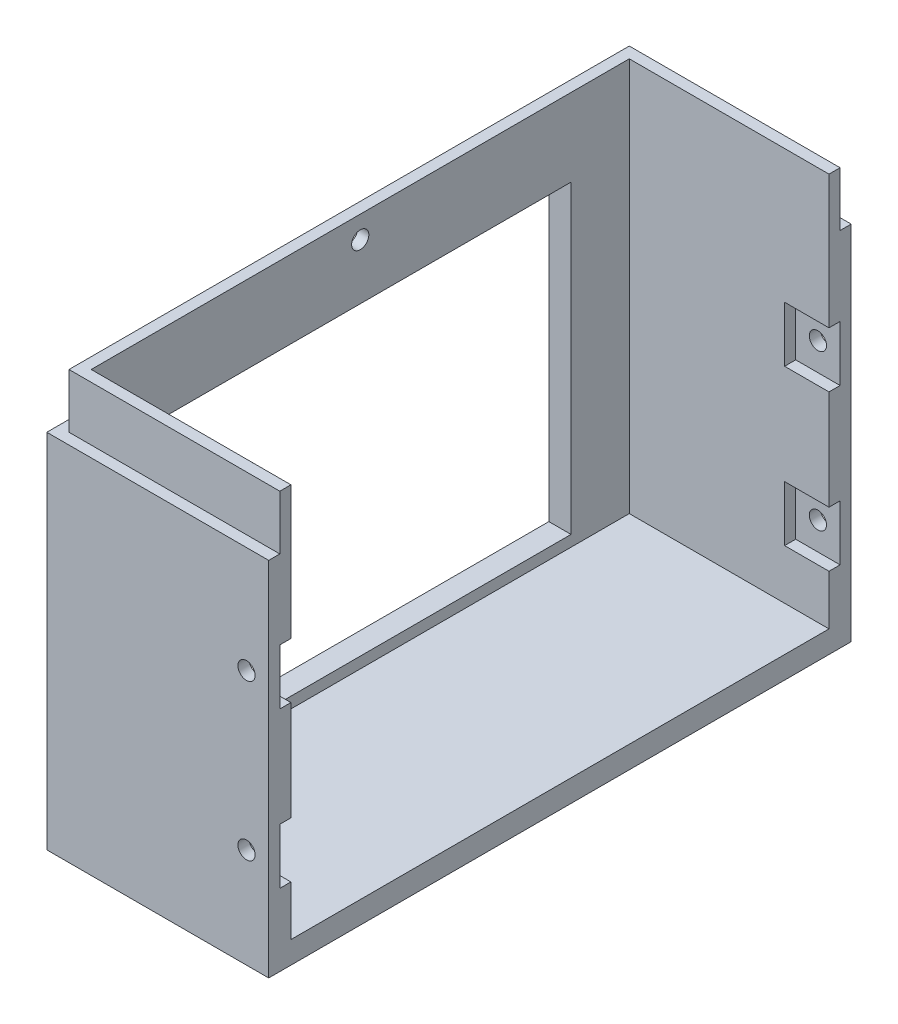
from build123d import *

# Parameters (mm, degrees)
SKETCH1_W               = 40
SKETCH1_H               = 105
BOSS_EXTRUDE3_DEPTH     = 75
SKETCH4_W               = 97
SKETCH4_H               = 71
CUT_EXTRUDE2_DEPTH      = 36
SKETCH5_W               = 40
SKETCH5_H               = 9.8
CUT_EXTRUDE3_DEPTH      = 2
SKETCH6_W               = 40
SKETCH6_H               = 9.8
CUT_EXTRUDE4_DEPTH      = 2
SKETCH7_W               = 101
SKETCH7_H               = 9.8
CUT_EXTRUDE5_DEPTH      = 2
SKETCH8_R               = 1.55
CUT_EXTRUDE6_DEPTH      = 102
CUT_EXTRUDE6_DEPTH_BACK = 5
SKETCH9_W               = 8
SKETCH9_H               = 10
CUT_EXTRUDE7_DEPTH      = 2
SKETCH10_R              = 1.55
CUT_EXTRUDE8_DEPTH      = 2
SKETCH11_W              = 8
SKETCH11_H              = 10
CUT_EXTRUDE9_DEPTH      = 2
CUT_EXTRUDE10_REACH     = 42
SKETCH12_W              = 76
SKETCH12_H              = 55


with BuildPart() as part:
    # Sketch1 → Boss-Extrude3 (new body)
    with BuildSketch(Plane(origin=(0, 0, 0), x_dir=(1, 0, 0), z_dir=(0, 1, 0))):
        Rectangle(SKETCH1_W, SKETCH1_H)
    extrude(amount=BOSS_EXTRUDE3_DEPTH)

    # Sketch4 → Cut-Extrude2 (cut)
    with BuildSketch(Plane(origin=(20, 0, 0), x_dir=(0, 0, -1), z_dir=(1, 0, 0))):
        with Locations((0, 39.5)):
            Rectangle(SKETCH4_W, SKETCH4_H)
    extrude(amount=-CUT_EXTRUDE2_DEPTH, mode=Mode.SUBTRACT)

    # Sketch5 → Cut-Extrude3 (cut)
    with BuildSketch(Plane.XY.offset(52.5)):
        with Locations((0, 70.1)):
            Rectangle(SKETCH5_W, SKETCH5_H)
    extrude(amount=-CUT_EXTRUDE3_DEPTH, mode=Mode.SUBTRACT)

    # Sketch6 → Cut-Extrude4 (cut)
    with BuildSketch(Plane(origin=(0, 0, -52.5), x_dir=(-1, 0, 0), z_dir=(0, 0, -1))):
        with Locations((0, 70.1)):
            Rectangle(SKETCH6_W, SKETCH6_H)
    extrude(amount=-CUT_EXTRUDE4_DEPTH, mode=Mode.SUBTRACT)

    # Sketch7 → Cut-Extrude5 (cut)
    with BuildSketch(Plane.ZY.offset(20)):
        with Locations((0, 70.1)):
            Rectangle(SKETCH7_W, SKETCH7_H)
    extrude(amount=-CUT_EXTRUDE5_DEPTH, mode=Mode.SUBTRACT)

    # Sketch8 → Cut-Extrude6 (cut, two sides)
    with BuildSketch(Plane(origin=(0, 0, 48.5), x_dir=(-1, 0, 0), z_dir=(0, 0, -1))) as cut_extrude6_sk:
        with Locations((-16, 18)):
            Circle(SKETCH8_R)
        with Locations((-16, 46)):
            Circle(SKETCH8_R)
    extrude(amount=CUT_EXTRUDE6_DEPTH, mode=Mode.SUBTRACT)
    extrude(cut_extrude6_sk.sketch, amount=-CUT_EXTRUDE6_DEPTH_BACK, mode=Mode.SUBTRACT)

    # Sketch9 → Cut-Extrude7 (cut)
    with BuildSketch(Plane(origin=(0, 0, 48.5), x_dir=(-1, 0, 0), z_dir=(0, 0, -1))):
        with Locations((-16, 18)):
            Rectangle(SKETCH9_W, SKETCH9_H)
        with Locations((-16, 46)):
            Rectangle(SKETCH9_W, SKETCH9_H)
    extrude(amount=-CUT_EXTRUDE7_DEPTH, mode=Mode.SUBTRACT)

    # Sketch10 → Cut-Extrude8 (cut)
    with BuildSketch(Plane.ZY.offset(18)):
        with Locations((0, 71)):
            Circle(SKETCH10_R)
    extrude(amount=-CUT_EXTRUDE8_DEPTH, mode=Mode.SUBTRACT)

    # Sketch11 → Cut-Extrude9 (cut)
    with BuildSketch(Plane.XY.offset(-48.5)):
        with Locations((16, 46)):
            Rectangle(SKETCH11_W, SKETCH11_H)
        with Locations((16, 18)):
            Rectangle(SKETCH11_W, SKETCH11_H)
    extrude(amount=-CUT_EXTRUDE9_DEPTH, mode=Mode.SUBTRACT)

    # Sketch12 → Cut-Extrude10 (cut, up to next)
    with BuildSketch(Plane.ZY.offset(20), mode=Mode.PRIVATE) as cut_extrude10_sk1:
        with Locations((0, 33.5)):
            Rectangle(SKETCH12_W, SKETCH12_H)
    cut_extrude10_tool1 = extrude(cut_extrude10_sk1.sketch, amount=-CUT_EXTRUDE10_REACH, mode=Mode.PRIVATE) & part.part
    add(cut_extrude10_tool1.solids().sort_by_distance((-20, 33.5, 0))[0], mode=Mode.SUBTRACT)


solid = part.part
